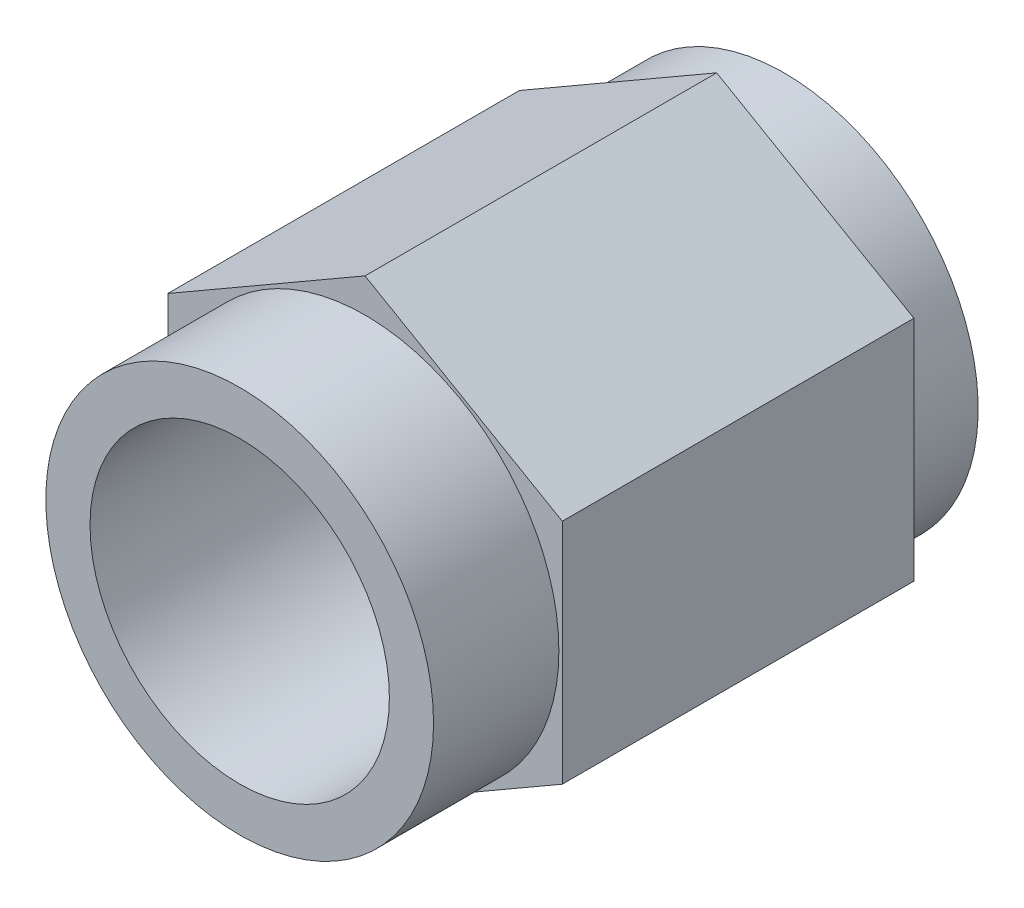
from build123d import *

# Parameters (mm, degrees)
BOSS_EXTRUDE1_DEPTH         = 11.811
SKETCH5_R                   = 5.461
BOSS_EXTRUDE3_DEPTH         = 3.5306
F_3_8_24_TAPPED_HOLE2_D     = 8.4328
F_3_8_24_TAPPED_HOLE2_DEPTH = 12.065
F_3_8_24_TAPPED_HOLE2_TIP   = 2.533468714
SKETCH9_R                   = 3.07975
CUT_EXTRUDE1_DEPTH          = 16.3416
SKETCH10_R                  = 4.1529
CUT_EXTRUDE2_DEPTH          = 4.445
SKETCH11_OUTSIDE_W          = 17.688
SKETCH11_OUTSIDE_H          = 19.408
SKETCH11_OUTSIDE_R          = 5.461
CUT_EXTRUDE3_DEPTH          = 1.905


with BuildPart() as part:
    # Sketch1 → Boss-Extrude1 (new body)
    with BuildSketch(Plane.XY):
        Polygon((5.55625, -3.207902433), (5.55625, 3.207902433), (0, 6.415804866), (-5.55625, 3.207902433), (-5.55625, -3.207902433), (0, -6.415804866), align=None)
    extrude(amount=BOSS_EXTRUDE1_DEPTH)

    # Sketch5 → Boss-Extrude3 (add)
    with BuildSketch(Plane.XY.offset(11.811)):
        Circle(SKETCH5_R)
    extrude(amount=BOSS_EXTRUDE3_DEPTH)

    # 3/8-24 Tapped Hole2
    with Locations(Plane.XY.offset(15.3416)):
        with Locations((0, 0)):
            Hole(F_3_8_24_TAPPED_HOLE2_D / 2, depth=F_3_8_24_TAPPED_HOLE2_DEPTH)
            with Locations((0, 0, -(F_3_8_24_TAPPED_HOLE2_DEPTH + F_3_8_24_TAPPED_HOLE2_TIP / 2))):  # 118° drill point
                Cone(0, F_3_8_24_TAPPED_HOLE2_D / 2, F_3_8_24_TAPPED_HOLE2_TIP, mode=Mode.SUBTRACT)

    # Sketch9 → Cut-Extrude1 (cut, through all)
    with BuildSketch(Plane(origin=(0, 0, 0), x_dir=(-1, 0, 0), z_dir=(0, 0, -1))):
        Circle(SKETCH9_R)
    extrude(amount=-CUT_EXTRUDE1_DEPTH, mode=Mode.SUBTRACT)

    # Sketch10 → Cut-Extrude2 (cut)
    with BuildSketch(Plane.XY.offset(5.8166)):
        Circle(SKETCH10_R)
    extrude(amount=-CUT_EXTRUDE2_DEPTH, mode=Mode.SUBTRACT)

    # Sketch11 outside → Cut-Extrude3 (cut)
    with BuildSketch(Plane(origin=(0, 0, 0), x_dir=(-1, 0, 0), z_dir=(0, 0, -1))):
        Rectangle(SKETCH11_OUTSIDE_W, SKETCH11_OUTSIDE_H)
        with Locations(Location((0, 0, 0), (0, 0, 180))):  # turned: the seam where the file's is
            Circle(SKETCH11_OUTSIDE_R, mode=Mode.SUBTRACT)
    extrude(amount=-CUT_EXTRUDE3_DEPTH, mode=Mode.SUBTRACT)


solid = part.part
